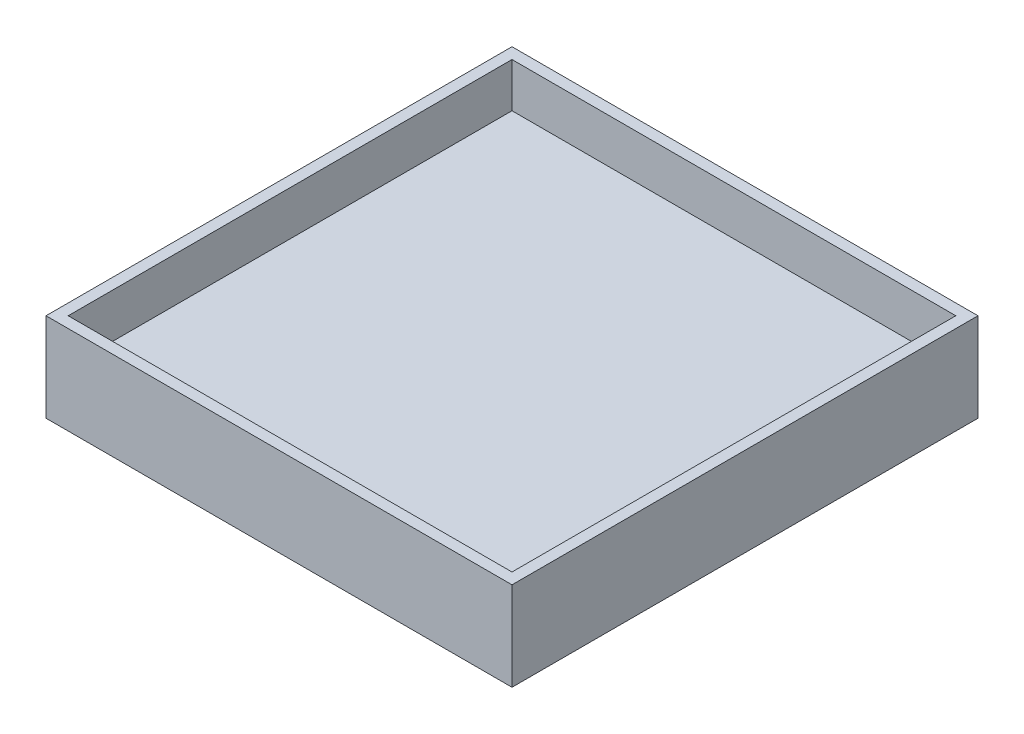
from build123d import *

# Parameters (mm, degrees)
SKETCH1_W                = 1000
SKETCH1_H                = 1000
BOSS_EXTRUDE1_DEPTH      = 100
SKETCH2_W                = 1050
SKETCH2_H                = 1050
SKETCH2_W_2              = 1000
SKETCH2_H_2              = 1000
BOSS_EXTRUDE3_DEPTH      = 200
SKETCH3_W                = 25
SKETCH3_H                = 30
BOSS_EXTRUDE4_DEPTH      = 25
FILLET1_R                = 2.5
FILLET2_R                = 10
SKETCH5_R                = 5
BOSS_EXTRUDE5_DEPTH      = 32.5
BOSS_EXTRUDE5_DEPTH_BACK = 32.5


with BuildPart() as part:
    # Sketch1 → Boss-Extrude1 (new body)
    with BuildSketch(Plane(origin=(0, 0, 0), x_dir=(1, 0, 0), z_dir=(0, 1, 0))):
        Rectangle(SKETCH1_W, SKETCH1_H)
    extrude(amount=BOSS_EXTRUDE1_DEPTH)

    # Sketch2 → Boss-Extrude3 (add)
    with BuildSketch(Plane(origin=(0, 0, 0), x_dir=(1, 0, 0), z_dir=(0, 1, 0))):
        Rectangle(SKETCH2_W, SKETCH2_H)
        Rectangle(SKETCH2_W_2, SKETCH2_H_2, mode=Mode.SUBTRACT)
    extrude(amount=BOSS_EXTRUDE3_DEPTH)

    # Sketch3 → Boss-Extrude4 (add)
    with BuildSketch(Plane.XZ):
        Rectangle(SKETCH3_W, SKETCH3_H)
    extrude(amount=BOSS_EXTRUDE4_DEPTH)

    # Fillet1
    fillet1_edges = [part.edges().sort_by_distance(p)[0] for p in [
        (12.5, 0, 0),
        (0, 0, 15),
        (-12.5, 0, 0),
        (0, 0, -15),
    ]]
    fillet(fillet1_edges, radius=FILLET1_R)

    # Fillet2
    fillet2_edges = [part.edges().sort_by_distance(p)[0] for p in [
        (12.5, -25, 0),
        (-12.5, -25, 0),
    ]]
    fillet(fillet2_edges, radius=FILLET2_R)

    # Sketch5 → Boss-Extrude5 (add, two sides)
    with BuildSketch(Plane.XY) as boss_extrude5_sk:
        with Locations((0, -17.5)):
            Circle(SKETCH5_R)
    extrude(amount=BOSS_EXTRUDE5_DEPTH)
    extrude(boss_extrude5_sk.sketch, amount=-BOSS_EXTRUDE5_DEPTH_BACK)


solid = part.part
